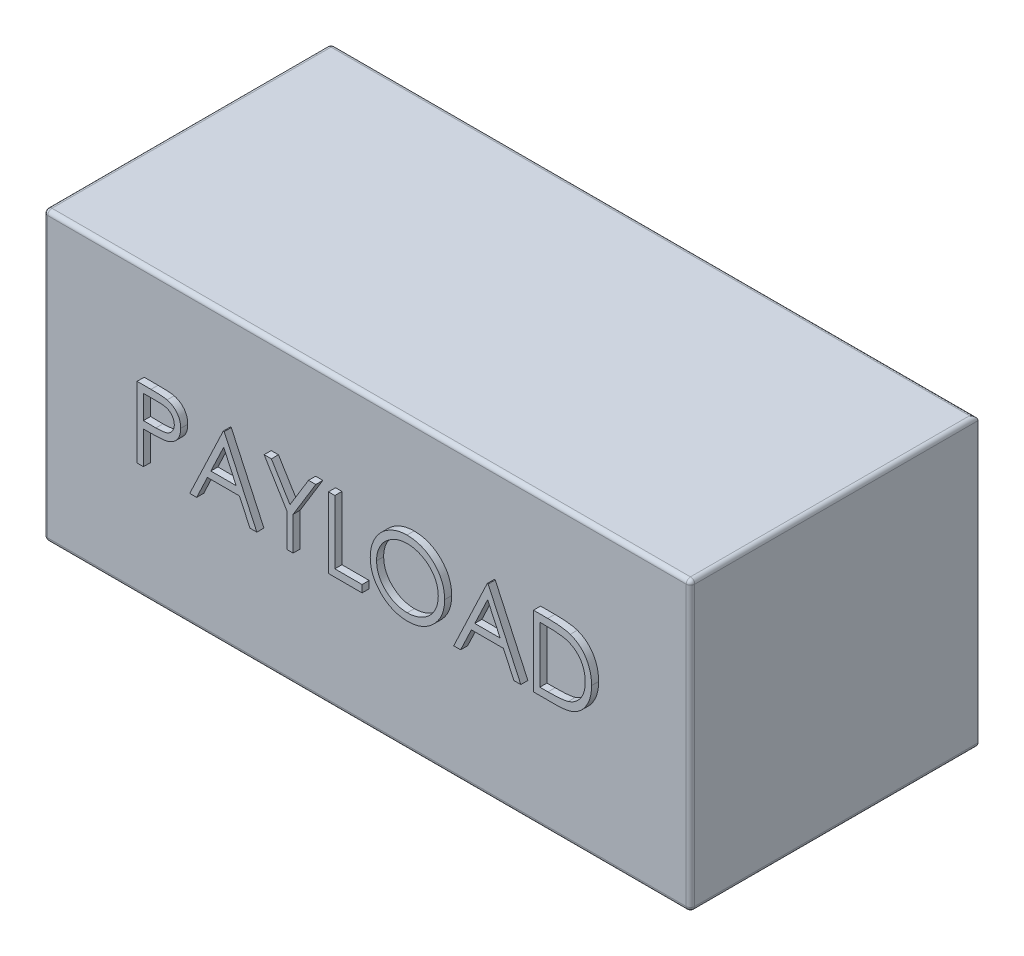
from build123d import *

# Parameters (mm, degrees)
SKETCH1_W           = 457.2
SKETCH1_H           = 203.2
BOSS_EXTRUDE1_DEPTH = 203.2
BOSS_EXTRUDE2_DEPTH = 5
BOSS_EXTRUDE3_DEPTH = 5
FILLET1_R           = 3


with BuildPart() as part:
    # Sketch1 → Boss-Extrude1 (new body)
    with BuildSketch(Plane.XY):
        Rectangle(SKETCH1_W, SKETCH1_H)
    extrude(amount=BOSS_EXTRUDE1_DEPTH)

    # Sketch2 → Boss-Extrude2 (add)
    with BuildSketch(Plane.XZ.offset(101.6)):
        with BuildLine():
            Line((-154.356741259, 121.087426038), (-144.551052156, 121.087426038))
            add(Edge.make_bspline(
                [(-144.551052156, 121.087426038), (-143.87661064, 121.086684664), (-142.584350742, 121.085264156), (-140.731278518, 121.042196359), (-139.048282352, 120.984672186), (-137.538991196, 120.904930855), (-136.198761223, 120.810693851), (-135.033656944, 120.67852186), (-134.034520425, 120.540517638), (-133.435856861, 120.400211831), (-133.162831002, 120.336224115)],
                knots=[0, 0, 0, 0, 0.002023262, 0.00387666, 0.005560425, 0.007074966, 0.008410857, 0.009589944, 0.010592848, 0.011433717, 0.011433717, 0.011433717, 0.011433717], degree=3))
            add(Edge.make_bspline(
                [(-133.162831002, 120.336224115), (-132.817209091, 120.241624832), (-132.134109417, 120.054655379), (-131.149808801, 119.680173615), (-130.213325294, 119.236142684), (-129.321445888, 118.730086401), (-128.485130415, 118.140292626), (-127.691901258, 117.490669516), (-126.948758683, 116.766218536), (-126.259881656, 115.97506511), (-125.62724169, 115.130490683), (-125.082531937, 114.219887399), (-124.626428694, 113.258583064), (-124.235239101, 112.247246333), (-123.953689752, 111.177384569), (-123.741591184, 110.056431535), (-123.606967933, 108.884507389), (-123.594074193, 108.083652139), (-123.587510489, 107.675967705)],
                knots=[0, 0, 0, 0, 0.001074519, 0.002123719, 0.003154202, 0.004181614, 0.005195808, 0.006220482, 0.007254609, 0.008305194, 0.009364907, 0.01041616, 0.011482385, 0.012553865, 0.013664245, 0.014795745, 0.015974832, 0.017197444, 0.017197444, 0.017197444, 0.017197444], degree=3))
            add(Edge.make_bspline(
                [(-123.587510489, 107.675967705), (-123.593530843, 107.264856608), (-123.60531007, 106.46048998), (-123.746685575, 105.283735863), (-123.937116884, 104.159187433), (-124.229931917, 103.08933814), (-124.613441533, 102.080541419), (-125.063328002, 101.117380962), (-125.605949865, 100.216242792), (-126.229447432, 99.373855399), (-126.923041637, 98.58942808), (-127.683797897, 97.868645301), (-128.508644932, 97.215726181), (-129.394961334, 96.629206986), (-130.351387745, 96.122688707), (-131.363418511, 95.669012922), (-132.439850174, 95.28799777), (-133.184743231, 95.087568321), (-133.563472028, 94.985663218)],
                knots=[0, 0, 0, 0, 0.001232622, 0.002411709, 0.003551249, 0.004651965, 0.005732814, 0.006785688, 0.007836942, 0.008882645, 0.009925708, 0.010974286, 0.012022337, 0.013077971, 0.014157938, 0.015265423, 0.016402716, 0.017579034, 0.017579034, 0.017579034, 0.017579034], degree=3))
            add(Edge.make_bspline(
                [(-133.563472028, 94.985663218), (-133.876719656, 94.919049202), (-134.563220047, 94.773060715), (-135.693830364, 94.61008276), (-137.01019302, 94.470974178), (-138.510511305, 94.366672213), (-140.193438518, 94.277381235), (-142.059885051, 94.206408465), (-144.113514725, 94.167410553), (-145.545961069, 94.165399227), (-146.293840618, 94.164349115)],
                knots=[0, 0, 0, 0, 0.000960547, 0.002105094, 0.003424665, 0.004931103, 0.006616208, 0.008480508, 0.010534184, 0.012777796, 0.012777796, 0.012777796, 0.012777796], degree=3))
            Line((-146.293840618, 94.164349115), (-149.869561771, 94.164349115))
            Line((-149.869561771, 94.164349115), (-149.869561771, 71.087426038))
            Line((-149.869561771, 71.087426038), (-154.356741259, 71.087426038))
            Line((-154.356741259, 71.087426038), (-154.356741259, 121.087426038))
        make_face()
        with BuildLine():
            Line((-149.869561771, 115.95922091), (-149.869561771, 99.292554244))
            Line((-149.869561771, 99.292554244), (-141.115555361, 99.182377961))
            add(Edge.make_bspline(
                [(-141.115555361, 99.182377961), (-140.68812785, 99.182157053), (-139.862987851, 99.181730594), (-138.671041804, 99.238662358), (-137.565194843, 99.304384253), (-136.548843766, 99.400611731), (-135.621530416, 99.536629695), (-134.781708575, 99.673940237), (-134.035890248, 99.872588274), (-133.163044509, 100.14006069), (-132.190425259, 100.596240914), (-131.132317423, 101.2583822), (-130.235594761, 102.102392318), (-129.459619093, 103.051361336), (-128.843820837, 104.107063185), (-128.393020946, 105.236619424), (-128.12814727, 106.428445846), (-128.092630217, 107.243990687), (-128.074689977, 107.655935654)],
                knots=[0, 0, 0, 0, 0.00128209, 0.002475049, 0.003579041, 0.004605573, 0.005536202, 0.006390857, 0.007156084, 0.007849798, 0.009127184, 0.010366301, 0.011578405, 0.012803231, 0.014033205, 0.015229145, 0.016439386, 0.017674651, 0.017674651, 0.017674651, 0.017674651], degree=3))
            add(Edge.make_bspline(
                [(-128.074689977, 107.655935654), (-128.092727784, 108.057914417), (-128.128584712, 108.856998448), (-128.395097043, 110.0281236), (-128.842944383, 111.14577652), (-129.463752877, 112.188249167), (-130.21719759, 113.13380351), (-131.092902492, 113.955191039), (-132.088806225, 114.615501078), (-133.015209526, 115.041690816), (-133.838083612, 115.301909037), (-134.552825896, 115.483978186), (-135.359835531, 115.629343989), (-136.259375239, 115.747051172), (-137.244472865, 115.847814904), (-138.32359165, 115.916186007), (-139.492643696, 115.956206811), (-140.30422328, 115.958191886), (-140.724930361, 115.95922091)],
                knots=[0, 0, 0, 0, 0.001205299, 0.002395985, 0.00358262, 0.004803959, 0.006022502, 0.007198948, 0.008390687, 0.009591817, 0.010244321, 0.010977956, 0.011803048, 0.012702541, 0.013699173, 0.014773179, 0.015945738, 0.017207797, 0.017207797, 0.017207797, 0.017207797], degree=3))
            Line((-140.724930361, 115.95922091), (-149.869561771, 115.95922091))
        make_face(mode=Mode.SUBTRACT)
        Polygon((-92.81827972, 121.087426038), (-69.741356643, 71.087426038), (-74.61916113, 71.087426038), (-82.010988053, 87.113067064), (-104.677254079, 87.113067064), (-112.279417541, 71.087426038), (-117.177254079, 71.087426038), (-93.459305361, 121.087426038), align=None)
        Polygon((-93.188872669, 111.34183309), (-102.243359848, 92.241272192), (-84.374770105, 92.241272192), align=None, mode=Mode.SUBTRACT)
        Polygon((-64.613151515, 121.087426038), (-59.474930361, 121.087426038), (-46.33390472, 99.603051038), (-33.21291113, 121.087426038), (-28.074689977, 121.087426038), (-44.100331002, 94.855454885), (-44.100331002, 71.087426038), (-48.587510489, 71.087426038), (-48.587510489, 94.855454885), align=None)
        Polygon((-19.100331002, 121.087426038), (-14.613151515, 121.087426038), (-14.613151515, 76.215631167), (4.617617716, 76.215631167), (4.617617716, 71.087426038), (-19.100331002, 71.087426038), align=None)
        with BuildLine():
            add(Edge.make_bspline(
                [(36.348386947, 122.36947732), (37.274217031, 122.346027615), (39.092623702, 122.299970459), (41.765122241, 121.947411837), (44.316480745, 121.337477695), (46.767482728, 120.525149373), (49.088810964, 119.441515297), (51.297938, 118.131727463), (53.389607626, 116.582063767), (55.335627362, 114.804503383), (57.116440938, 112.870454042), (58.68538217, 110.806483898), (60.00027208, 108.625072436), (61.08006904, 106.332774856), (61.927192036, 103.934775313), (62.511749803, 101.41828956), (62.885151948, 98.799622559), (62.928805911, 97.013524491), (62.950951049, 96.10745809)],
                knots=[0, 0, 0, 0, 0.002777041, 0.005454338, 0.008068425, 0.01063716, 0.01318702, 0.015737884, 0.018330081, 0.020981964, 0.023633205, 0.026207343, 0.028746163, 0.031259727, 0.033797105, 0.036360151, 0.038999083, 0.041716086, 0.041716086, 0.041716086, 0.041716086], degree=3))
            add(Edge.make_bspline(
                [(62.950951049, 96.10745809), (62.928809156, 95.208065999), (62.885164919, 93.435259993), (62.51132524, 90.83321079), (61.925025241, 88.331915126), (61.087935724, 85.935548658), (60.013286031, 83.641583461), (58.689640729, 81.456055549), (57.130480576, 79.378248429), (55.35609699, 77.43092464), (53.42179639, 75.645246487), (51.347078292, 74.089262549), (49.178602293, 72.750346483), (46.888463605, 71.682008284), (44.507034508, 70.828123706), (42.013001321, 70.245943277), (39.418050549, 69.870414088), (37.64846478, 69.827292431), (36.749027972, 69.805374756)],
                knots=[0, 0, 0, 0, 0.00269699, 0.005316081, 0.007869381, 0.010393996, 0.012916623, 0.015455444, 0.018045589, 0.020697472, 0.023348712, 0.025930847, 0.028466307, 0.03097987, 0.033498358, 0.036041916, 0.038651085, 0.041348076, 0.041348076, 0.041348076, 0.041348076], degree=3))
            add(Edge.make_bspline(
                [(36.749027972, 69.805374756), (35.842966272, 69.827508854), (34.056877473, 69.871141053), (31.434919825, 70.245161122), (28.916666342, 70.83003689), (26.509318467, 71.665885979), (24.211533758, 72.746132132), (22.018818291, 74.063337548), (19.939973331, 75.626296707), (17.992234095, 77.400104916), (16.210102693, 79.331127087), (14.656397326, 81.400187874), (13.338895707, 83.566694398), (12.262276671, 85.836659028), (11.409927252, 88.199108209), (10.82842985, 90.669800745), (10.452201963, 93.234650828), (10.408847014, 94.980977947), (10.386848485, 95.867073474)],
                knots=[0, 0, 0, 0, 0.002717003, 0.005355936, 0.007928729, 0.010462803, 0.01298543, 0.015532831, 0.018122976, 0.020774859, 0.023426099, 0.025994209, 0.02852446, 0.031019918, 0.033519534, 0.036043612, 0.038623026, 0.041279992, 0.041279992, 0.041279992, 0.041279992], degree=3))
            add(Edge.make_bspline(
                [(10.386848485, 95.867073474), (10.394486135, 96.461825891), (10.409665083, 97.643827655), (10.592403547, 99.3990648), (10.857570707, 101.126074197), (11.237598029, 102.819944882), (11.734621843, 104.476530378), (12.321079377, 106.107255561), (13.037362882, 107.695594472), (13.847086426, 109.249071496), (14.75082654, 110.743470151), (15.749051532, 112.156035624), (16.806699653, 113.498621293), (17.966176705, 114.736435633), (19.189268779, 115.905487867), (20.495817039, 116.987812396), (21.877849101, 117.993168839), (23.341311669, 118.899173711), (24.850144167, 119.71858992), (26.405526707, 120.42175922), (27.986334871, 121.025274384), (29.599972699, 121.51442903), (31.242155157, 121.900600973), (32.916466365, 122.163563168), (34.621572455, 122.34676771), (35.770305583, 122.361874881), (36.348386947, 122.36947732)],
                knots=[0, 0, 0, 0, 0.001783556, 0.003544611, 0.005288464, 0.007023435, 0.008747414, 0.010474271, 0.012218383, 0.013970071, 0.015727334, 0.017452942, 0.019156402, 0.020850296, 0.022536442, 0.02422924, 0.025936201, 0.027659336, 0.029389182, 0.031083519, 0.032776316, 0.034461928, 0.036138318, 0.037832715, 0.039543932, 0.041277428, 0.041277428, 0.041277428, 0.041277428], degree=3))
        make_face()
        with BuildLine():
            add(Edge.make_bspline(
                [(36.568739511, 117.241272192), (36.094244746, 117.235488046), (35.149791418, 117.22397505), (33.745726615, 117.07232197), (32.36012756, 116.856180699), (30.9927081, 116.54787326), (29.649189681, 116.127815363), (28.317049092, 115.644373817), (27.008434037, 115.055501094), (25.727664639, 114.390176746), (24.486020708, 113.653763592), (23.314410688, 112.839881206), (22.209801488, 111.967616145), (21.174897679, 111.034932754), (20.212738076, 110.0370813), (19.304385198, 108.989189355), (18.486248318, 107.861305197), (17.736454363, 106.684013671), (17.065485216, 105.458848225), (16.468837292, 104.198707335), (15.980780023, 102.89331181), (15.582746076, 101.556823845), (15.252748778, 100.191360135), (15.04369272, 98.786562295), (14.890373299, 97.349489266), (14.879518364, 96.378319922), (14.874027972, 95.887105526)],
                knots=[0, 0, 0, 0, 0.00142284, 0.002832077, 0.004231743, 0.005628862, 0.007032428, 0.008452092, 0.00987789, 0.011333835, 0.012780172, 0.014205477, 0.015610187, 0.017000143, 0.018381374, 0.019766522, 0.021156839, 0.022557257, 0.023951357, 0.025344881, 0.026736387, 0.028127462, 0.02952684, 0.030946292, 0.032385431, 0.033858332, 0.033858332, 0.033858332, 0.033858332], degree=3))
            add(Edge.make_bspline(
                [(14.874027972, 95.887105526), (14.892240286, 95.164788086), (14.928069541, 93.743766225), (15.241749114, 91.661364169), (15.724920178, 89.660102936), (16.43716827, 87.750932803), (17.327891336, 85.917443048), (18.428275483, 84.175898696), (19.731976705, 82.525829062), (21.212884228, 80.978753791), (22.831780037, 79.566670873), (24.550819036, 78.327193607), (26.351584857, 77.278475752), (28.238773467, 76.424117575), (30.202309739, 75.747121321), (32.254846182, 75.283140876), (34.382709891, 74.977777228), (35.833147822, 74.948452143), (36.568739511, 74.933579885)],
                knots=[0, 0, 0, 0, 0.002165779, 0.004260757, 0.006303756, 0.008331847, 0.01036105, 0.012409076, 0.014498972, 0.016659673, 0.018824919, 0.020934713, 0.023008224, 0.025065634, 0.027140306, 0.029227344, 0.031370516, 0.033575884, 0.033575884, 0.033575884, 0.033575884], degree=3))
            add(Edge.make_bspline(
                [(36.568739511, 74.933579885), (37.063160962, 74.940372804), (38.043747196, 74.953845204), (39.502254658, 75.089540587), (40.934486254, 75.307138722), (42.33843311, 75.620433802), (43.712501844, 76.012536751), (45.062427603, 76.478361436), (46.37383175, 77.059521488), (47.663258005, 77.701635082), (48.897490029, 78.433637333), (50.075711919, 79.219896614), (51.168225916, 80.09087691), (52.202355508, 81.009702803), (53.168465351, 81.99490063), (54.060022268, 83.045189513), (54.874024156, 84.167198902), (55.623533394, 85.342704698), (56.292151433, 86.571222594), (56.874709991, 87.835932279), (57.368940217, 89.133719556), (57.767918857, 90.466456291), (58.08056831, 91.831611274), (58.295995737, 93.23101239), (58.446687718, 94.66186014), (58.458045963, 95.629629511), (58.463771562, 96.117474115)],
                knots=[0, 0, 0, 0, 0.001482913, 0.002941062, 0.004390205, 0.005826413, 0.007253126, 0.008675437, 0.010106362, 0.011553184, 0.012994413, 0.014408412, 0.015799053, 0.017182317, 0.018556375, 0.019935026, 0.021311346, 0.022711764, 0.024114651, 0.025503957, 0.026886096, 0.028277171, 0.029674289, 0.031083847, 0.032522987, 0.033985875, 0.033985875, 0.033985875, 0.033985875], degree=3))
            add(Edge.make_bspline(
                [(58.463771562, 96.117474115), (58.458041376, 96.601981319), (58.446674498, 97.563090607), (58.296067718, 98.983959441), (58.080340713, 100.373291034), (57.769444883, 101.725631076), (57.368728402, 103.041324292), (56.874623682, 104.319134973), (56.291976546, 105.563823474), (55.623287627, 106.772313431), (54.871633005, 107.931952545), (54.050286672, 109.040558439), (53.145067413, 110.077311886), (52.181838487, 111.067807515), (51.136540125, 111.990920224), (50.013907352, 112.846956233), (48.827569098, 113.656574437), (47.571465735, 114.386939607), (46.275123539, 115.061428645), (44.944924139, 115.639300119), (43.595937002, 116.130330396), (42.23159254, 116.549144182), (40.840407135, 116.854973184), (39.431781009, 117.072516754), (38.007663029, 117.223922266), (37.049902747, 117.235470531), (36.568739511, 117.241272192)],
                knots=[0, 0, 0, 0, 0.001452876, 0.002882048, 0.004281713, 0.005669068, 0.007040971, 0.008404402, 0.009775537, 0.011160866, 0.01254442, 0.013918625, 0.015296183, 0.016670242, 0.018060991, 0.019475345, 0.020903252, 0.022366826, 0.023831668, 0.025284958, 0.026714024, 0.028136758, 0.02956319, 0.030982641, 0.032411812, 0.033854676, 0.033854676, 0.033854676, 0.033854676], degree=3))
        make_face(mode=Mode.SUBTRACT)
        Polygon((93.720181818, 121.087426038), (116.797104895, 71.087426038), (111.919300408, 71.087426038), (104.527473485, 87.113067064), (81.861207459, 87.113067064), (74.259043998, 71.087426038), (69.361207459, 71.087426038), (93.079156177, 121.087426038), align=None)
        Polygon((93.34958887, 111.34183309), (84.29510169, 92.241272192), (102.163691434, 92.241272192), align=None, mode=Mode.SUBTRACT)
        with BuildLine():
            Line((125.77146387, 71.087426038), (125.77146387, 121.087426038))
            Line((125.77146387, 121.087426038), (135.867617716, 121.087426038))
            add(Edge.make_bspline(
                [(135.867617716, 121.087426038), (136.745746119, 121.08110361), (138.442285623, 121.068888711), (140.893892015, 120.991440266), (143.162231479, 120.854433611), (145.239843752, 120.654868952), (147.132432494, 120.409825615), (148.834698325, 120.102676981), (150.355443223, 119.739988833), (151.290720946, 119.430768115), (151.733002331, 119.284541423)],
                knots=[0, 0, 0, 0, 0.002634386, 0.00508962, 0.007357581, 0.009450523, 0.011350112, 0.013080915, 0.014638077, 0.016035052, 0.016035052, 0.016035052, 0.016035052], degree=3))
            add(Edge.make_bspline(
                [(151.733002331, 119.284541423), (152.311498607, 119.064102771), (153.455372782, 118.628224284), (155.084045962, 117.805991408), (156.617265433, 116.874375669), (158.063253217, 115.832149059), (159.388979308, 114.649801223), (160.646234976, 113.377557143), (161.783588173, 111.969152283), (162.825135259, 110.453795311), (163.764216109, 108.849337423), (164.580489792, 107.15883587), (165.258403983, 105.390875755), (165.821164363, 103.550373641), (166.264685185, 101.633282529), (166.567284209, 99.637370157), (166.766869779, 97.570524594), (166.786927655, 96.168032255), (166.797104895, 95.456416423)],
                knots=[0, 0, 0, 0, 0.00185621, 0.003670328, 0.005463672, 0.007234697, 0.009008919, 0.010786729, 0.012595058, 0.01443149, 0.016298801, 0.018166864, 0.020056684, 0.021973516, 0.023936683, 0.025953912, 0.02802597, 0.03016023, 0.03016023, 0.03016023, 0.03016023], degree=3))
            add(Edge.make_bspline(
                [(166.797104895, 95.456416423), (166.788119646, 94.83839873), (166.770413273, 93.620530317), (166.611423046, 91.82566038), (166.380332759, 90.084037932), (166.022558505, 88.403956503), (165.588236884, 86.770696247), (165.031606151, 85.201664185), (164.393956206, 83.682466909), (163.650386512, 82.233645824), (162.834081012, 80.86102622), (161.958056109, 79.567090104), (161.023246175, 78.370301221), (160.020737134, 77.267035334), (158.963484041, 76.258955643), (157.844565033, 75.337641138), (156.661092879, 74.521118926), (155.418368269, 73.777303094), (154.080137851, 73.128440873), (152.621054049, 72.579440733), (151.034894363, 72.124489084), (149.325552121, 71.744904859), (147.490073868, 71.443800535), (145.526660071, 71.241994929), (143.438327361, 71.105524462), (142.004337857, 71.093575985), (141.266255536, 71.087426038)],
                knots=[0, 0, 0, 0, 0.001853641, 0.003652794, 0.005402161, 0.007120982, 0.008802362, 0.010468579, 0.012111237, 0.013741759, 0.015349573, 0.016899729, 0.018426508, 0.019901348, 0.021367833, 0.022805473, 0.024244717, 0.025677323, 0.027146644, 0.028699935, 0.030348173, 0.032092917, 0.033950316, 0.035924693, 0.038012092, 0.040225996, 0.040225996, 0.040225996, 0.040225996], degree=3))
            Line((141.266255536, 71.087426038), (125.77146387, 71.087426038))
        make_face()
        with BuildLine():
            Line((130.258643357, 76.215631167), (135.997826049, 76.215631167))
            add(Edge.make_bspline(
                [(135.997826049, 76.215631167), (136.82251706, 76.219175401), (138.408699894, 76.22599226), (140.689528427, 76.285809448), (142.773519805, 76.383551412), (144.660969939, 76.520338238), (146.350813143, 76.701318455), (147.846580999, 76.90310278), (149.143370404, 77.154494934), (149.928076646, 77.382365782), (150.290694639, 77.487666423)],
                knots=[0, 0, 0, 0, 0.002474039, 0.004758484, 0.006844224, 0.00873245, 0.010434733, 0.01194187, 0.01325992, 0.014392262, 0.014392262, 0.014392262, 0.014392262], degree=3))
            add(Edge.make_bspline(
                [(150.290694639, 77.487666423), (150.747099811, 77.648402969), (151.649008928, 77.966036873), (152.947310145, 78.545432033), (154.158124498, 79.231747315), (155.30255343, 79.994636943), (156.364362794, 80.861008401), (157.356135884, 81.812022526), (158.275875903, 82.852519313), (159.114080303, 83.981207335), (159.864198932, 85.191061559), (160.513787924, 86.470187754), (161.083095518, 87.804570757), (161.529932555, 89.214701595), (161.880155186, 90.687973858), (162.128222157, 92.224491191), (162.282718221, 93.823966646), (162.300738906, 94.911854135), (162.309925408, 95.466432449)],
                knots=[0, 0, 0, 0, 0.001451322, 0.002867979, 0.004258187, 0.00562217, 0.006989348, 0.008363626, 0.009740237, 0.011150507, 0.012576375, 0.014005336, 0.015450735, 0.016923636, 0.01843715, 0.019989925, 0.021589544, 0.023252958, 0.023252958, 0.023252958, 0.023252958], degree=3))
            add(Edge.make_bspline(
                [(162.309925408, 95.466432449), (162.302592731, 96.051196453), (162.288187623, 97.199970515), (162.107126046, 98.885551876), (161.842532396, 100.506704027), (161.45990831, 102.063535389), (160.972324326, 103.559083278), (160.363829444, 104.98507628), (159.668592026, 106.356574407), (158.841401499, 107.641922489), (157.935464451, 108.857538334), (156.930066175, 109.971179985), (155.84117991, 110.985384275), (154.680682061, 111.915945884), (153.415866358, 112.725426968), (152.076527918, 113.449522412), (150.643018329, 114.064035146), (149.645694103, 114.390876042), (149.13885169, 114.55697732)],
                knots=[0, 0, 0, 0, 0.00175352, 0.003444805, 0.005079904, 0.006678363, 0.008249379, 0.009793407, 0.011325433, 0.012856444, 0.014372872, 0.015869287, 0.017350339, 0.018833252, 0.020325136, 0.021848757, 0.023396711, 0.024996299, 0.024996299, 0.024996299, 0.024996299], degree=3))
            add(Edge.make_bspline(
                [(149.13885169, 114.55697732), (148.719549599, 114.67292629), (147.827998309, 114.919465612), (146.373148823, 115.188399506), (144.735789546, 115.425606634), (142.908650958, 115.626435768), (140.893815828, 115.770540358), (138.689734571, 115.878701996), (136.295454506, 115.951653888), (134.635704023, 115.95663542), (133.774268357, 115.95922091)],
                knots=[0, 0, 0, 0, 0.001304585, 0.002773906, 0.00443403, 0.00626792, 0.008286739, 0.010493018, 0.012887874, 0.015472087, 0.015472087, 0.015472087, 0.015472087], degree=3))
            Line((133.774268357, 115.95922091), (130.258643357, 115.95922091))
            Line((130.258643357, 115.95922091), (130.258643357, 76.215631167))
        make_face(mode=Mode.SUBTRACT)
    extrude(amount=BOSS_EXTRUDE2_DEPTH)

    # Sketch3 → Boss-Extrude3 (add)
    with BuildSketch(Plane.XY.offset(203.2)):
        with BuildLine():
            Line((-157.444672648, 33.74593702), (-147.638983545, 33.74593702))
            add(Edge.make_bspline(
                [(-147.638983545, 33.74593702), (-146.964542029, 33.745195645), (-145.672282132, 33.743775138), (-143.819209907, 33.700707341), (-142.136213741, 33.643183168), (-140.626922585, 33.563441837), (-139.286692612, 33.469204833), (-138.121588333, 33.337032842), (-137.122451814, 33.19902862), (-136.523788251, 33.058722812), (-136.250762392, 32.994735097)],
                knots=[0, 0, 0, 0, 0.002023262, 0.00387666, 0.005560425, 0.007074966, 0.008410857, 0.009589944, 0.010592848, 0.011433717, 0.011433717, 0.011433717, 0.011433717], degree=3))
            add(Edge.make_bspline(
                [(-136.250762392, 32.994735097), (-135.90514048, 32.900135814), (-135.222040806, 32.713166361), (-134.23774019, 32.338684597), (-133.301256683, 31.894653666), (-132.409377277, 31.388597382), (-131.573061805, 30.798803608), (-130.779832648, 30.149180498), (-130.036690072, 29.424729518), (-129.347813045, 28.633576092), (-128.71517308, 27.789001665), (-128.170463327, 26.87839838), (-127.714360083, 25.917094046), (-127.323170491, 24.905757315), (-127.041621141, 23.835895551), (-126.829522574, 22.714942517), (-126.694899322, 21.543018371), (-126.682005583, 20.742163121), (-126.675441879, 20.334478687)],
                knots=[0, 0, 0, 0, 0.001074519, 0.002123719, 0.003154202, 0.004181614, 0.005195808, 0.006220482, 0.007254609, 0.008305194, 0.009364907, 0.01041616, 0.011482385, 0.012553865, 0.013664245, 0.014795745, 0.015974832, 0.017197444, 0.017197444, 0.017197444, 0.017197444], degree=3))
            add(Edge.make_bspline(
                [(-126.675441879, 20.334478687), (-126.681462232, 19.92336759), (-126.69324146, 19.119000962), (-126.834616965, 17.942246845), (-127.025048273, 16.817698415), (-127.317863307, 15.747849122), (-127.701372922, 14.739052401), (-128.151259392, 13.775891944), (-128.693881254, 12.874753774), (-129.317378821, 12.03236638), (-130.010973027, 11.247939062), (-130.771729286, 10.527156283), (-131.596576322, 9.874237163), (-132.482892723, 9.287717967), (-133.439319135, 8.781199689), (-134.4513499, 8.327523904), (-135.527781563, 7.946508752), (-136.27267462, 7.746079303), (-136.651403417, 7.6441742)],
                knots=[0, 0, 0, 0, 0.001232622, 0.002411709, 0.003551249, 0.004651965, 0.005732814, 0.006785688, 0.007836942, 0.008882645, 0.009925708, 0.010974286, 0.012022337, 0.013077971, 0.014157938, 0.015265423, 0.016402716, 0.017579034, 0.017579034, 0.017579034, 0.017579034], degree=3))
            add(Edge.make_bspline(
                [(-136.651403417, 7.6441742), (-136.964651046, 7.577560184), (-137.651151437, 7.431571696), (-138.781761753, 7.268593741), (-140.09812441, 7.12948516), (-141.598442694, 7.025183195), (-143.281369907, 6.935892217), (-145.14781644, 6.864919447), (-147.201446114, 6.825921535), (-148.633892458, 6.823910209), (-149.381772007, 6.822860097)],
                knots=[0, 0, 0, 0, 0.000960547, 0.002105094, 0.003424665, 0.004931103, 0.006616208, 0.008480508, 0.010534184, 0.012777796, 0.012777796, 0.012777796, 0.012777796], degree=3))
            Line((-149.381772007, 6.822860097), (-152.957493161, 6.822860097))
            Line((-152.957493161, 6.822860097), (-152.957493161, -16.25406298))
            Line((-152.957493161, -16.25406298), (-157.444672648, -16.25406298))
            Line((-157.444672648, -16.25406298), (-157.444672648, 33.74593702))
        make_face()
        with BuildLine():
            Line((-152.957493161, 28.617731892), (-152.957493161, 11.951065225))
            Line((-152.957493161, 11.951065225), (-144.203486751, 11.840888943))
            add(Edge.make_bspline(
                [(-144.203486751, 11.840888943), (-143.776059239, 11.840668035), (-142.95091924, 11.840241576), (-141.758973194, 11.89717334), (-140.653126232, 11.962895235), (-139.636775156, 12.059122713), (-138.709461806, 12.195140677), (-137.869639965, 12.332451219), (-137.123821638, 12.531099256), (-136.250975898, 12.798571672), (-135.278356648, 13.254751896), (-134.220248812, 13.916893182), (-133.32352615, 14.760903299), (-132.547550482, 15.709872318), (-131.931752226, 16.765574167), (-131.480952336, 17.895130406), (-131.216078659, 19.086956828), (-131.180561607, 19.902501669), (-131.162621366, 20.314446636)],
                knots=[0, 0, 0, 0, 0.00128209, 0.002475049, 0.003579041, 0.004605573, 0.005536202, 0.006390857, 0.007156084, 0.007849798, 0.009127184, 0.010366301, 0.011578405, 0.012803231, 0.014033205, 0.015229145, 0.016439386, 0.017674651, 0.017674651, 0.017674651, 0.017674651], degree=3))
            add(Edge.make_bspline(
                [(-131.162621366, 20.314446636), (-131.180659173, 20.716425399), (-131.216516101, 21.51550943), (-131.483028432, 22.686634581), (-131.930875773, 23.804287501), (-132.551684266, 24.846760149), (-133.30512898, 25.792314492), (-134.180833881, 26.613702021), (-135.176737615, 27.27401206), (-136.103140915, 27.700201798), (-136.926015001, 27.960420018), (-137.640757285, 28.142489168), (-138.447766921, 28.287854971), (-139.347306628, 28.405562154), (-140.332404255, 28.506325886), (-141.411523039, 28.574696989), (-142.580575086, 28.614717793), (-143.392154669, 28.616702868), (-143.812861751, 28.617731892)],
                knots=[0, 0, 0, 0, 0.001205299, 0.002395985, 0.00358262, 0.004803959, 0.006022502, 0.007198948, 0.008390687, 0.009591817, 0.010244321, 0.010977956, 0.011803048, 0.012702541, 0.013699173, 0.014773179, 0.015945738, 0.017207797, 0.017207797, 0.017207797, 0.017207797], degree=3))
            Line((-143.812861751, 28.617731892), (-152.957493161, 28.617731892))
        make_face(mode=Mode.SUBTRACT)
        Polygon((-95.90621111, 33.74593702), (-72.829288033, -16.25406298), (-77.70709252, -16.25406298), (-85.098919443, -0.228421954), (-107.765185469, -0.228421954), (-115.36734893, -16.25406298), (-120.265185469, -16.25406298), (-96.547236751, 33.74593702), align=None)
        Polygon((-96.276804058, 24.000344071), (-105.331291238, 4.899783174), (-87.462701494, 4.899783174), align=None, mode=Mode.SUBTRACT)
        Polygon((-67.701082904, 33.74593702), (-62.562861751, 33.74593702), (-49.42183611, 12.26156202), (-36.30084252, 33.74593702), (-31.162621366, 33.74593702), (-47.188262392, 7.513965866), (-47.188262392, -16.25406298), (-51.675441879, -16.25406298), (-51.675441879, 7.513965866), align=None)
        Polygon((-22.188262392, 33.74593702), (-17.701082904, 33.74593702), (-17.701082904, -11.125857852), (1.529686326, -11.125857852), (1.529686326, -16.25406298), (-22.188262392, -16.25406298), align=None)
        with BuildLine():
            add(Edge.make_bspline(
                [(33.260455557, 35.027988302), (34.186285641, 35.004538597), (36.004692312, 34.958481441), (38.677190851, 34.605922819), (41.228549355, 33.995988676), (43.679551338, 33.183660355), (46.000879575, 32.100026278), (48.21000661, 30.790238445), (50.301676237, 29.240574748), (52.247695973, 27.463014365), (54.028509548, 25.528965023), (55.597450781, 23.464994879), (56.912340691, 21.283583418), (57.99213765, 18.991285837), (58.839260646, 16.593286295), (59.423818413, 14.076800541), (59.797220558, 11.45813354), (59.840874521, 9.672035473), (59.86301966, 8.765969071)],
                knots=[0, 0, 0, 0, 0.002777041, 0.005454338, 0.008068425, 0.01063716, 0.01318702, 0.015737884, 0.018330081, 0.020981964, 0.023633205, 0.026207343, 0.028746163, 0.031259727, 0.033797105, 0.036360151, 0.038999083, 0.041716086, 0.041716086, 0.041716086, 0.041716086], degree=3))
            add(Edge.make_bspline(
                [(59.86301966, 8.765969071), (59.840877766, 7.866576981), (59.79723353, 6.093770974), (59.423393851, 3.491721772), (58.837093851, 0.990426108), (58.000004334, -1.40594036), (56.925354642, -3.699905557), (55.60170934, -5.885433469), (54.042549187, -7.963240589), (52.2681656, -9.910564378), (50.333865, -11.696242531), (48.259146903, -13.252226469), (46.090670904, -14.591142535), (43.800532216, -15.659480734), (41.419103118, -16.513365312), (38.925069932, -17.095545741), (36.330119159, -17.471074931), (34.560533391, -17.514196587), (33.661096583, -17.536114262)],
                knots=[0, 0, 0, 0, 0.00269699, 0.005316081, 0.007869381, 0.010393996, 0.012916623, 0.015455444, 0.018045589, 0.020697472, 0.023348712, 0.025930847, 0.028466307, 0.03097987, 0.033498358, 0.036041916, 0.038651085, 0.041348076, 0.041348076, 0.041348076, 0.041348076], degree=3))
            add(Edge.make_bspline(
                [(33.661096583, -17.536114262), (32.755034883, -17.513980164), (30.968946084, -17.470347965), (28.346988436, -17.096327896), (25.828734952, -16.511452128), (23.421387078, -15.675603039), (21.123602369, -14.595356886), (18.930886902, -13.278151471), (16.852041941, -11.715192311), (14.904302706, -9.941384103), (13.122171303, -8.010361931), (11.568465936, -5.941301144), (10.250964317, -3.774794621), (9.174345282, -1.50482999), (8.321995863, 0.857619191), (7.740498461, 3.328311727), (7.364270574, 5.89316181), (7.320915624, 7.639488929), (7.298917096, 8.525584456)],
                knots=[0, 0, 0, 0, 0.002717003, 0.005355936, 0.007928729, 0.010462803, 0.01298543, 0.015532831, 0.018122976, 0.020774859, 0.023426099, 0.025994209, 0.02852446, 0.031019918, 0.033519534, 0.036043612, 0.038623026, 0.041279992, 0.041279992, 0.041279992, 0.041279992], degree=3))
            add(Edge.make_bspline(
                [(7.298917096, 8.525584456), (7.306554746, 9.120336872), (7.321733693, 10.302338637), (7.504472157, 12.057575782), (7.769639317, 13.784585178), (8.149666639, 15.478455864), (8.646690454, 17.135041359), (9.233147988, 18.765766543), (9.949431493, 20.354105453), (10.759155036, 21.907582478), (11.662895151, 23.401981133), (12.661120143, 24.814546606), (13.718768264, 26.157132275), (14.878245316, 27.394946615), (16.10133739, 28.563998849), (17.407885649, 29.646323378), (18.789917711, 30.65167982), (20.25338028, 31.557684693), (21.762212778, 32.377100902), (23.317595318, 33.080270201), (24.898403482, 33.683785366), (26.512041309, 34.172940012), (28.154223768, 34.559111954), (29.828534976, 34.82207415), (31.533641066, 35.005278691), (32.682374193, 35.020385863), (33.260455557, 35.027988302)],
                knots=[0, 0, 0, 0, 0.001783556, 0.003544611, 0.005288464, 0.007023435, 0.008747414, 0.010474271, 0.012218383, 0.013970071, 0.015727334, 0.017452942, 0.019156402, 0.020850296, 0.022536442, 0.02422924, 0.025936201, 0.027659336, 0.029389182, 0.031083519, 0.032776316, 0.034461928, 0.036138318, 0.037832715, 0.039543932, 0.041277428, 0.041277428, 0.041277428, 0.041277428], degree=3))
        make_face()
        with BuildLine():
            add(Edge.make_bspline(
                [(33.480808121, 29.899783174), (33.006313356, 29.893999028), (32.061860029, 29.882486031), (30.657795225, 29.730832952), (29.27219617, 29.514691681), (27.904776711, 29.206384241), (26.561258291, 28.786326345), (25.229117703, 28.302884799), (23.920502648, 27.714012076), (22.63973325, 27.048687728), (21.398089319, 26.312274574), (20.226479298, 25.498392187), (19.121870099, 24.626127127), (18.086966289, 23.693443736), (17.124806687, 22.695592282), (16.216453809, 21.647700337), (15.398316928, 20.519816179), (14.648522974, 19.342524653), (13.977553827, 18.117359207), (13.380905902, 16.857218317), (12.892848634, 15.551822792), (12.494814687, 14.215334826), (12.164817389, 12.849871117), (11.95576133, 11.445073276), (11.80244191, 10.008000247), (11.791586975, 9.036830904), (11.786096583, 8.545616507)],
                knots=[0, 0, 0, 0, 0.00142284, 0.002832077, 0.004231743, 0.005628862, 0.007032428, 0.008452092, 0.00987789, 0.011333835, 0.012780172, 0.014205477, 0.015610187, 0.017000143, 0.018381374, 0.019766522, 0.021156839, 0.022557257, 0.023951357, 0.025344881, 0.026736387, 0.028127462, 0.02952684, 0.030946292, 0.032385431, 0.033858332, 0.033858332, 0.033858332, 0.033858332], degree=3))
            add(Edge.make_bspline(
                [(11.786096583, 8.545616507), (11.804308896, 7.823299067), (11.840138152, 6.402277206), (12.153817725, 4.319875151), (12.636988788, 2.318613917), (13.34923688, 0.409443785), (14.239959947, -1.42404597), (15.340344094, -3.165590323), (16.644045316, -4.815659956), (18.124952839, -6.362735227), (19.743848647, -7.774818145), (21.462887646, -9.014295412), (23.263653468, -10.063013266), (25.150842078, -10.917371443), (27.11437835, -11.594367697), (29.166914793, -12.058348142), (31.294778501, -12.36371179), (32.745216432, -12.393036875), (33.480808121, -12.407909134)],
                knots=[0, 0, 0, 0, 0.002165779, 0.004260757, 0.006303756, 0.008331847, 0.01036105, 0.012409076, 0.014498972, 0.016659673, 0.018824919, 0.020934713, 0.023008224, 0.025065634, 0.027140306, 0.029227344, 0.031370516, 0.033575884, 0.033575884, 0.033575884, 0.033575884], degree=3))
            add(Edge.make_bspline(
                [(33.480808121, -12.407909134), (33.975229573, -12.401116214), (34.955815807, -12.387643815), (36.414323269, -12.251948431), (37.846554865, -12.034350297), (39.25050172, -11.721055217), (40.624570455, -11.328952268), (41.974496213, -10.863127582), (43.285900361, -10.28196753), (44.575326615, -9.639853936), (45.809558639, -8.907851685), (46.987780529, -8.121592404), (48.080294527, -7.250612109), (49.114424119, -6.331786215), (50.080533962, -5.346588389), (50.972090879, -4.296299505), (51.786092767, -3.174290116), (52.535602004, -1.99878432), (53.204220044, -0.770266424), (53.786778601, 0.494443261), (54.281008828, 1.792230537), (54.679987468, 3.124967273), (54.992636921, 4.490122255), (55.208064348, 5.889523372), (55.358756329, 7.320371122), (55.370114574, 8.288140493), (55.375840172, 8.775985097)],
                knots=[0, 0, 0, 0, 0.001482913, 0.002941062, 0.004390205, 0.005826413, 0.007253126, 0.008675437, 0.010106362, 0.011553184, 0.012994413, 0.014408412, 0.015799053, 0.017182317, 0.018556375, 0.019935026, 0.021311346, 0.022711764, 0.024114651, 0.025503957, 0.026886096, 0.028277171, 0.029674289, 0.031083847, 0.032522987, 0.033985875, 0.033985875, 0.033985875, 0.033985875], degree=3))
            add(Edge.make_bspline(
                [(55.375840172, 8.775985097), (55.370109987, 9.260492301), (55.358743109, 10.221601589), (55.208136328, 11.642470423), (54.992409323, 13.031802015), (54.681513494, 14.384142058), (54.280797012, 15.699835273), (53.786692292, 16.977645955), (53.204045157, 18.222334456), (52.535356237, 19.430824413), (51.783701616, 20.590463527), (50.962355283, 21.69906942), (50.057136024, 22.735822868), (49.093907097, 23.726318497), (48.048608735, 24.649431206), (46.925975963, 25.505467215), (45.739637709, 26.315085419), (44.483534346, 27.045450588), (43.18719215, 27.719939627), (41.85699275, 28.297811101), (40.508005613, 28.788841378), (39.143661151, 29.207655164), (37.752475746, 29.513484166), (36.343849619, 29.731027735), (34.91973164, 29.882433248), (33.961971358, 29.893981513), (33.480808121, 29.899783174)],
                knots=[0, 0, 0, 0, 0.001452876, 0.002882048, 0.004281713, 0.005669068, 0.007040971, 0.008404402, 0.009775537, 0.011160866, 0.01254442, 0.013918625, 0.015296183, 0.016670242, 0.018060991, 0.019475345, 0.020903252, 0.022366826, 0.023831668, 0.025284958, 0.026714024, 0.028136758, 0.02956319, 0.030982641, 0.032411812, 0.033854676, 0.033854676, 0.033854676, 0.033854676], degree=3))
        make_face(mode=Mode.SUBTRACT)
        Polygon((90.632250429, 33.74593702), (113.709173506, -16.25406298), (108.831369019, -16.25406298), (101.439542096, -0.228421954), (78.77327607, -0.228421954), (71.171112608, -16.25406298), (66.27327607, -16.25406298), (89.991224788, 33.74593702), align=None)
        Polygon((90.26165748, 24.000344071), (81.207170301, 4.899783174), (99.075760044, 4.899783174), align=None, mode=Mode.SUBTRACT)
        with BuildLine():
            Line((122.68353248, -16.25406298), (122.68353248, 33.74593702))
            Line((122.68353248, 33.74593702), (132.779686326, 33.74593702))
            add(Edge.make_bspline(
                [(132.779686326, 33.74593702), (133.657814729, 33.739614592), (135.354354234, 33.727399693), (137.805960626, 33.649951248), (140.07430009, 33.512944593), (142.151912362, 33.313379934), (144.044501105, 33.068336596), (145.746766935, 32.761187963), (147.267511834, 32.398499814), (148.202789557, 32.089279097), (148.645070942, 31.943052405)],
                knots=[0, 0, 0, 0, 0.002634386, 0.00508962, 0.007357581, 0.009450523, 0.011350112, 0.013080915, 0.014638077, 0.016035052, 0.016035052, 0.016035052, 0.016035052], degree=3))
            add(Edge.make_bspline(
                [(148.645070942, 31.943052405), (149.223567218, 31.722613753), (150.367441393, 31.286735266), (151.996114573, 30.46450239), (153.529334044, 29.53288665), (154.975321827, 28.49066004), (156.301047919, 27.308312205), (157.558303587, 26.036068125), (158.695656784, 24.627663264), (159.73720387, 23.112306293), (160.676284719, 21.507848404), (161.492558403, 19.817346852), (162.170472593, 18.049386737), (162.733232973, 16.208884622), (163.176753795, 14.291793511), (163.47935282, 12.295881138), (163.678938389, 10.229035576), (163.698996265, 8.826543237), (163.709173506, 8.114927405)],
                knots=[0, 0, 0, 0, 0.00185621, 0.003670328, 0.005463672, 0.007234697, 0.009008919, 0.010786729, 0.012595058, 0.01443149, 0.016298801, 0.018166864, 0.020056684, 0.021973516, 0.023936683, 0.025953912, 0.02802597, 0.03016023, 0.03016023, 0.03016023, 0.03016023], degree=3))
            add(Edge.make_bspline(
                [(163.709173506, 8.114927405), (163.700188256, 7.496909712), (163.682481883, 6.279041299), (163.523491656, 4.484171361), (163.29240137, 2.742548914), (162.934627115, 1.062467484), (162.500305495, -0.570792771), (161.943674762, -2.139824833), (161.306024817, -3.659022109), (160.562455123, -5.107843194), (159.746149623, -6.480462799), (158.87012472, -7.774398915), (157.935314786, -8.971187798), (156.932805744, -10.074453684), (155.875552652, -11.082533375), (154.756633644, -12.00384788), (153.57316149, -12.820370092), (152.330436879, -13.564185924), (150.992206462, -14.213048146), (149.533122659, -14.762048286), (147.946962974, -15.216999934), (146.237620732, -15.59658416), (144.402142479, -15.897688483), (142.438728681, -16.099494089), (140.350395971, -16.235964556), (138.916406468, -16.247913033), (138.178324147, -16.25406298)],
                knots=[0, 0, 0, 0, 0.001853641, 0.003652794, 0.005402161, 0.007120982, 0.008802362, 0.010468579, 0.012111237, 0.013741759, 0.015349573, 0.016899729, 0.018426508, 0.019901348, 0.021367833, 0.022805473, 0.024244717, 0.025677323, 0.027146644, 0.028699935, 0.030348173, 0.032092917, 0.033950316, 0.035924693, 0.038012092, 0.040225996, 0.040225996, 0.040225996, 0.040225996], degree=3))
            Line((138.178324147, -16.25406298), (122.68353248, -16.25406298))
        make_face()
        with BuildLine():
            Line((127.170711967, -11.125857852), (132.90989466, -11.125857852))
            add(Edge.make_bspline(
                [(132.90989466, -11.125857852), (133.73458567, -11.122313618), (135.320768505, -11.115496758), (137.601597037, -11.05567957), (139.685588416, -10.957937606), (141.57303855, -10.82115078), (143.262881754, -10.640170563), (144.758649609, -10.438386238), (146.055439014, -10.186994085), (146.840145256, -9.959123236), (147.202763249, -9.853822595)],
                knots=[0, 0, 0, 0, 0.002474039, 0.004758484, 0.006844224, 0.00873245, 0.010434733, 0.01194187, 0.01325992, 0.014392262, 0.014392262, 0.014392262, 0.014392262], degree=3))
            add(Edge.make_bspline(
                [(147.202763249, -9.853822595), (147.659168422, -9.693086049), (148.561077539, -9.375452145), (149.859378756, -8.796056986), (151.070193108, -8.109741703), (152.214622041, -7.346852075), (153.276431404, -6.480480618), (154.268204494, -5.529466492), (155.187944514, -4.488969705), (156.026148914, -3.360281683), (156.776267543, -2.150427459), (157.425856534, -0.871301264), (157.995164128, 0.463081739), (158.442001166, 1.873212577), (158.792223797, 3.34648484), (159.040290768, 4.883002172), (159.194786831, 6.482477627), (159.212807516, 7.570365117), (159.221994019, 8.12494343)],
                knots=[0, 0, 0, 0, 0.001451322, 0.002867979, 0.004258187, 0.00562217, 0.006989348, 0.008363626, 0.009740237, 0.011150507, 0.012576375, 0.014005336, 0.015450735, 0.016923636, 0.01843715, 0.019989925, 0.021589544, 0.023252958, 0.023252958, 0.023252958, 0.023252958], degree=3))
            add(Edge.make_bspline(
                [(159.221994019, 8.12494343), (159.214661342, 8.709707435), (159.200256234, 9.858481497), (159.019194656, 11.544062858), (158.754601006, 13.165215008), (158.37197692, 14.722046371), (157.884392937, 16.217594259), (157.275898054, 17.643587262), (156.580660636, 19.015085389), (155.75347011, 20.300433471), (154.847533062, 21.516049316), (153.842134786, 22.629690967), (152.753248521, 23.643895256), (151.592750672, 24.574456866), (150.327934968, 25.38393795), (148.988596528, 26.108033394), (147.55508694, 26.722546128), (146.557762714, 27.049387024), (146.050920301, 27.215488302)],
                knots=[0, 0, 0, 0, 0.00175352, 0.003444805, 0.005079904, 0.006678363, 0.008249379, 0.009793407, 0.011325433, 0.012856444, 0.014372872, 0.015869287, 0.017350339, 0.018833252, 0.020325136, 0.021848757, 0.023396711, 0.024996299, 0.024996299, 0.024996299, 0.024996299], degree=3))
            add(Edge.make_bspline(
                [(146.050920301, 27.215488302), (145.63161821, 27.331437272), (144.74006692, 27.577976594), (143.285217434, 27.846910487), (141.647858156, 28.084117616), (139.820719569, 28.28494675), (137.805884439, 28.42905134), (135.601803182, 28.537212978), (133.207523117, 28.61016487), (131.547772633, 28.615146402), (130.686336967, 28.617731892)],
                knots=[0, 0, 0, 0, 0.001304585, 0.002773906, 0.00443403, 0.00626792, 0.008286739, 0.010493018, 0.012887874, 0.015472087, 0.015472087, 0.015472087, 0.015472087], degree=3))
            Line((130.686336967, 28.617731892), (127.170711967, 28.617731892))
            Line((127.170711967, 28.617731892), (127.170711967, -11.125857852))
        make_face(mode=Mode.SUBTRACT)
    extrude(amount=BOSS_EXTRUDE3_DEPTH)

    # Fillet1
    fillet1_edges = [part.edges().sort_by_distance(p)[0] for p in [
        (-228.6, 0, 203.2),
        (0, -101.6, 203.2),
        (228.6, 0, 203.2),
        (0, -101.6, 0),
        (-228.6, 0, 0),
        (0, 101.6, 0),
        (0, 101.6, 203.2),
        (228.6, -101.6, 101.6),
        (-228.6, -101.6, 101.6),
        (-228.6, 101.6, 101.6),
        (228.6, 101.6, 101.6),
    ]]
    fillet(fillet1_edges, radius=FILLET1_R)


solid = part.part
